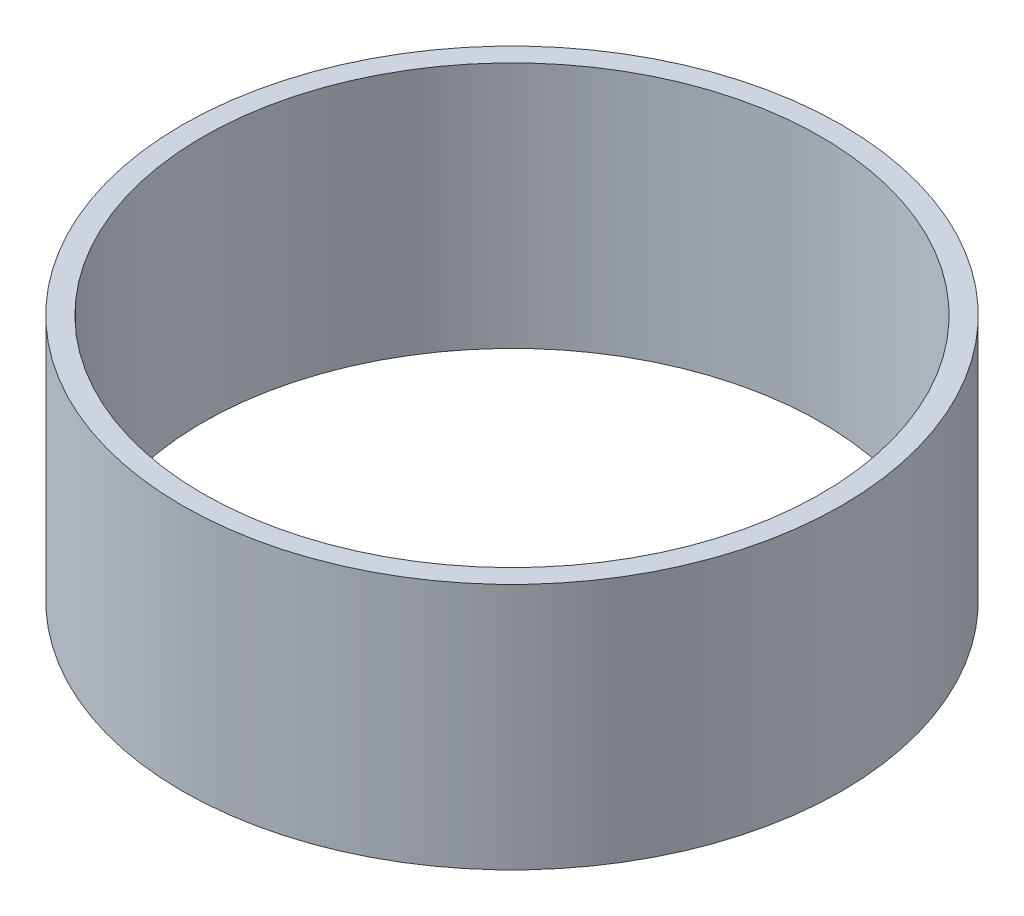
from build123d import *

# Parameters (mm, degrees)
CROQUIS2_R              = 40
CROQUIS2_R_2            = 37.5
SALIENTE_EXTRUIR1_DEPTH = 30


with BuildPart() as part:
    # Croquis2 → Saliente-Extruir1 (new body)
    with BuildSketch(Plane(origin=(0, 0, 0), x_dir=(1, 0, 0), z_dir=(0, 1, 0))):
        Circle(CROQUIS2_R)
        Circle(CROQUIS2_R_2, mode=Mode.SUBTRACT)
    extrude(amount=SALIENTE_EXTRUIR1_DEPTH)


solid = part.part
